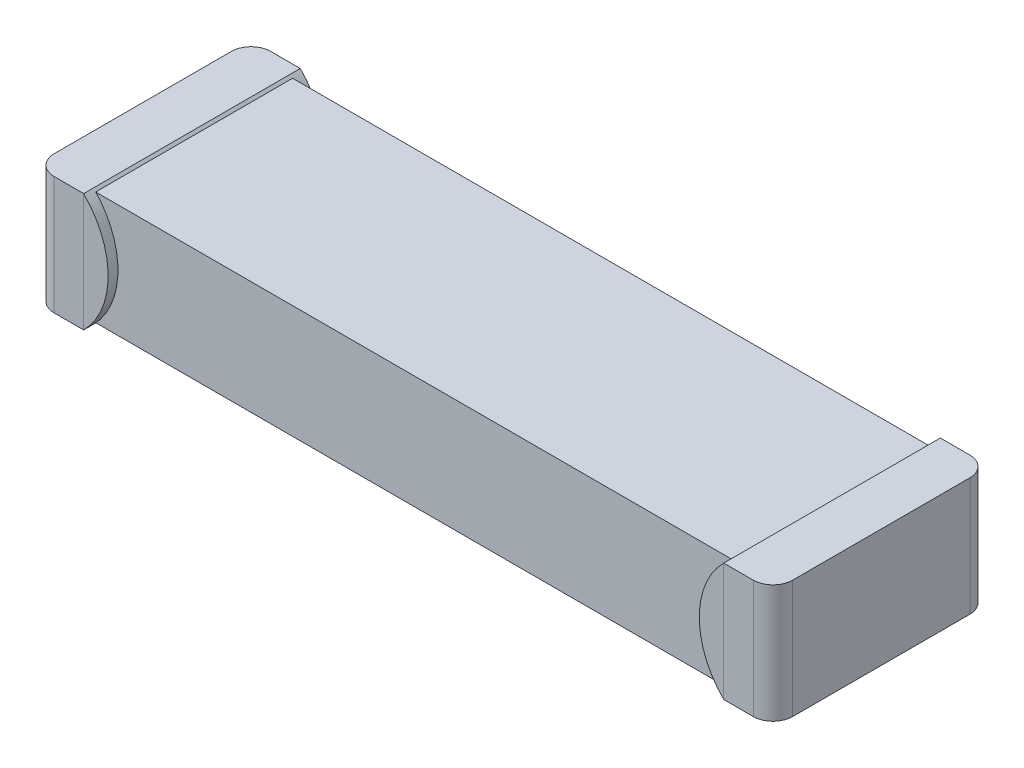
from build123d import *

# Parameters (mm, degrees)
BOSS_EXTRUDE1_START   = -0.025
SKETCH1_W             = 7.5
SKETCH1_H             = 2
BOSS_EXTRUDE1_DEPTH   = 1.15
BOSS_EXTRUDE2_START   = -0.05
SKETCH2_W             = 0.5
SKETCH2_H             = 2.2
BOSS_EXTRUDE2_DEPTH   = 1.2
FILLET1_R             = 0.2
BOSS_EXTRUDE3_DEPTH   = 2.2
BOSS_EXTRUDE3_2_DEPTH = 2.2


with BuildPart() as part:
    # Sketch1 → Boss-Extrude1 (new body)
    with BuildSketch(Plane(origin=(0, 0, 0), x_dir=(1, 0, 0), z_dir=(0, 1, 0)).offset(BOSS_EXTRUDE1_START)):
        with Locations((3.75, 1)):
            Rectangle(SKETCH1_W, SKETCH1_H)
    extrude(amount=BOSS_EXTRUDE1_DEPTH)

    # Sketch2 → Boss-Extrude2 (add)
    with BuildSketch(Plane(origin=(0, 0, 0), x_dir=(1, 0, 0), z_dir=(0, 1, 0)).offset(BOSS_EXTRUDE2_START)):
        with Locations((7.250073079, 1)):
            Rectangle(SKETCH2_W, SKETCH2_H)
        with Locations((0.25, 1)):
            Rectangle(SKETCH2_W, SKETCH2_H)
    extrude(amount=BOSS_EXTRUDE2_DEPTH)

    # Fillet1
    fillet1_edges = [part.edges().sort_by_distance(p)[0] for p in [
        (7.500073079, 0.55, 0.1),
        (7.500073079, 0.55, -2.1),
        (0, 0.55, -2.1),
        (0, 0.55, 0.1),
    ]]
    fillet(fillet1_edges, radius=FILLET1_R)


with BuildPart() as body_2:
    # Sketch3 → Boss-Extrude3 (new body)
    with BuildSketch(Plane.XY.offset(0.1)):
        with BuildLine():
            Line((7.000073079, 1.15), (7.000073079, -0.05))
            ThreePointArc((7.000073079, -0.05), (6.751544941, 0.55), (7.000073079, 1.15))
        make_face()
    extrude(amount=-BOSS_EXTRUDE3_DEPTH)


with BuildPart() as body_3:
    # Sketch3 → Boss-Extrude3 2 (new body)
    with BuildSketch(Plane.XY.offset(0.1)):
        with BuildLine():
            Line((0.5, 1.15), (0.5, -0.05))
            ThreePointArc((0.5, -0.05), (0.748528137, 0.55), (0.5, 1.15))
        make_face()
    extrude(amount=-BOSS_EXTRUDE3_2_DEPTH)


solid = Compound([part.part, body_2.part, body_3.part])
